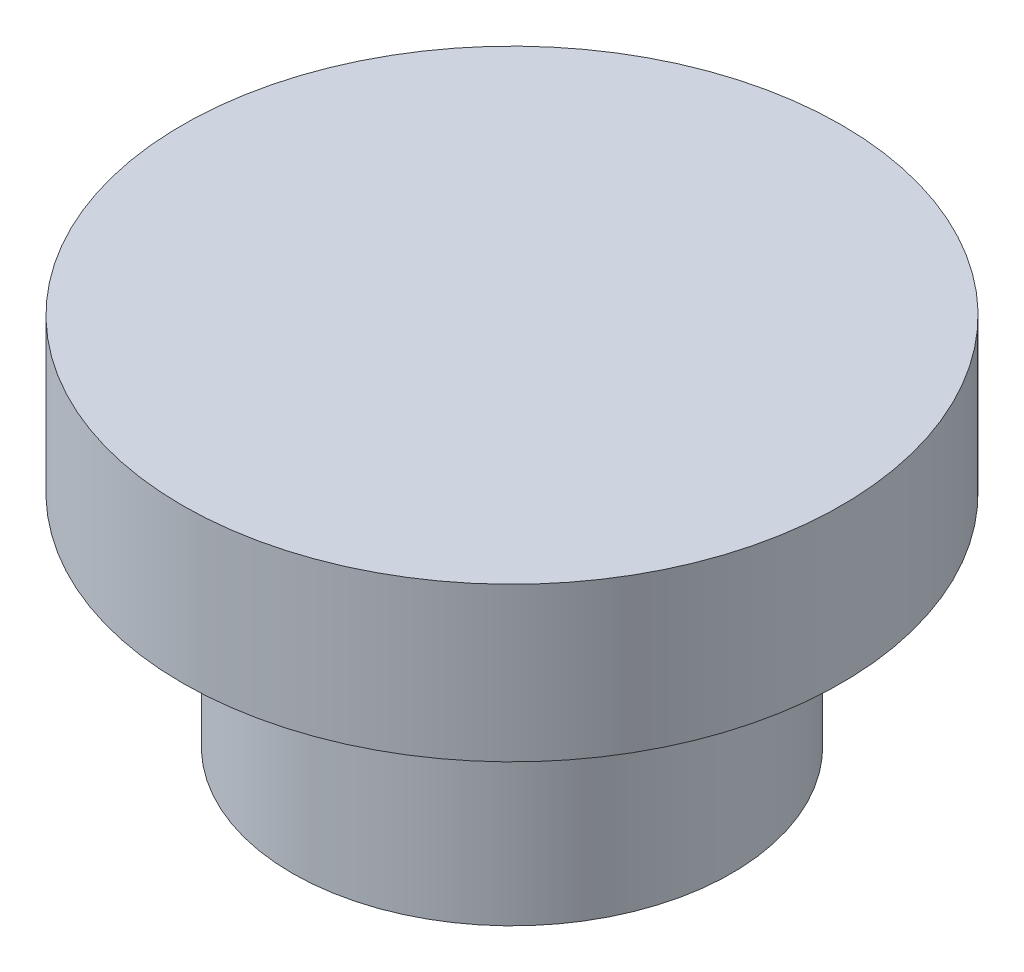
from build123d import *

# Parameters (mm, degrees)
SKETCH_1_R      = 15
EXTRUDE_1_DEPTH = 7
SKETCH_2_R      = 10
EXTRUDE_2_DEPTH = 10


with BuildPart() as part:
    # 草图1 → 凸台-拉伸1 (new body)
    with BuildSketch(Plane(origin=(0, 0, 0), x_dir=(1, 0, 0), z_dir=(0, 1, 0))):
        Circle(SKETCH_1_R)
    extrude(amount=EXTRUDE_1_DEPTH)

    # 草图2 → 凸台-拉伸2 (add)
    with BuildSketch(Plane(origin=(0, 0, 0), x_dir=(-1, 0, 0), z_dir=(0, -1, 0))):
        Circle(SKETCH_2_R)
    extrude(amount=EXTRUDE_2_DEPTH)


solid = part.part
